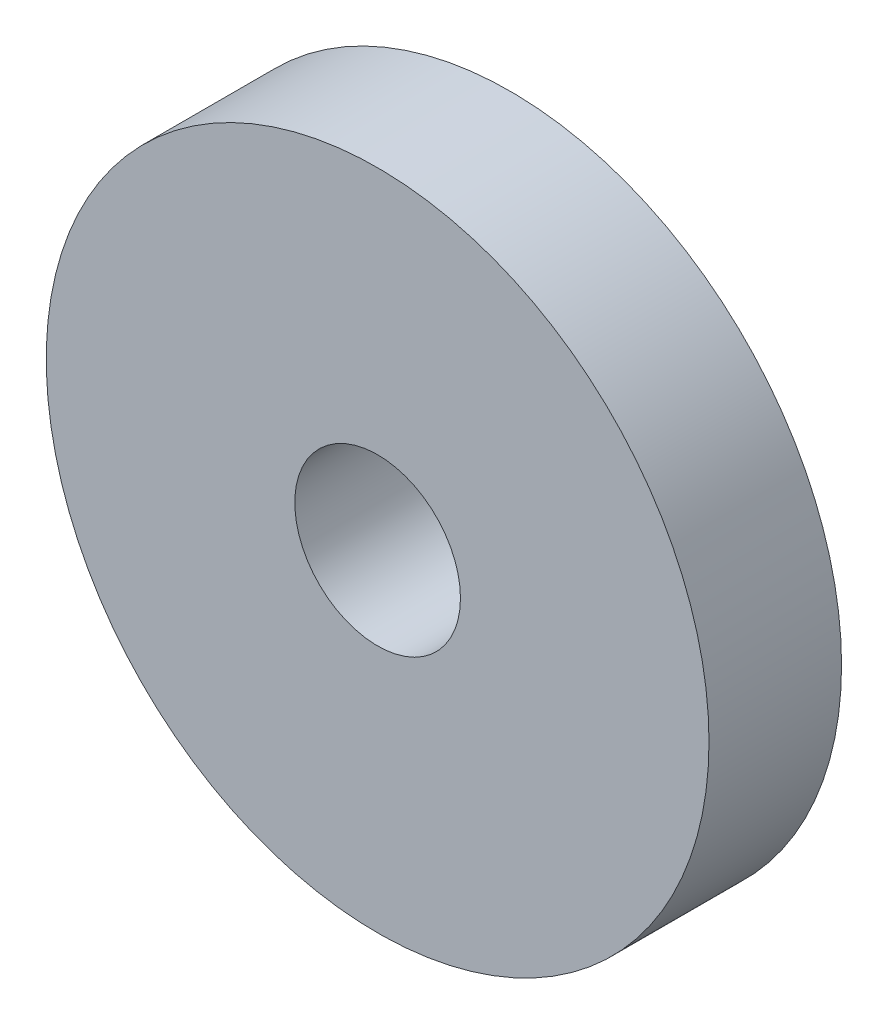
from build123d import *

# Parameters (mm, degrees)
MODEL_R             = 5
MODEL_R_2           = 1.25
BOSS_EXTRUDE1_DEPTH = 2


with BuildPart() as part:
    # Model → Boss-Extrude1 (new body)
    with BuildSketch(Plane.XY):
        Circle(MODEL_R)
        Circle(MODEL_R_2, mode=Mode.SUBTRACT)
    extrude(amount=BOSS_EXTRUDE1_DEPTH)


solid = part.part
